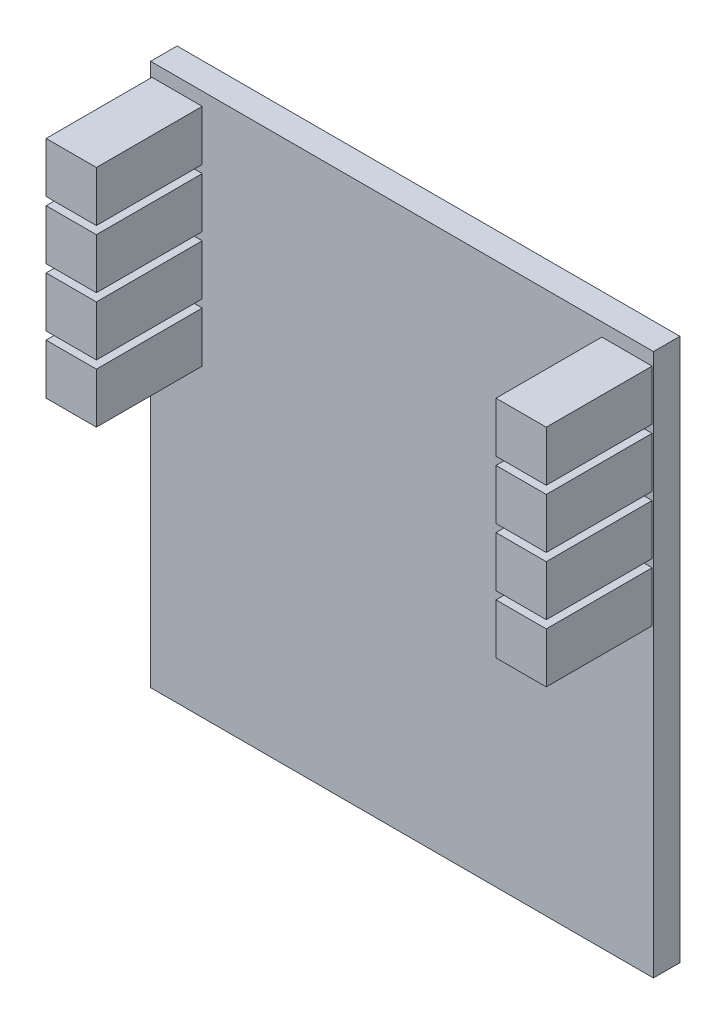
from build123d import *

# Parameters (mm, degrees)
SKETCH_1_W        = 19
SKETCH_1_H        = 20.5
EXTRUDE_1_DEPTH   = 1
SKETCH_2_W        = 1.9
SKETCH_2_H        = 1.9
EXTRUDE_2_DEPTH   = 4
EXTRUDE_2_2_DEPTH = 4
EXTRUDE_2_3_DEPTH = 4
EXTRUDE_2_4_DEPTH = 4
EXTRUDE_2_5_DEPTH = 4
EXTRUDE_2_6_DEPTH = 4
EXTRUDE_2_7_DEPTH = 4
EXTRUDE_2_8_DEPTH = 4
SKETCH_3_W        = 9
SKETCH_3_H        = 8
EXTRUDE_3_DEPTH   = 2.5
SKETCH_4_W        = 1.5
SKETCH_4_H        = 8
EXTRUDE_4_DEPTH   = 6


with BuildPart() as part:
    # ｽｹｯﾁ1 → ﾎﾞｽ - 押し出し1 (new body)
    with BuildSketch(Plane.XY):
        with Locations((9.5, 10.25)):
            Rectangle(SKETCH_1_W, SKETCH_1_H)
    extrude(amount=EXTRUDE_1_DEPTH)


with BuildPart() as body_2:
    # ｽｹｯﾁ2 → ﾎﾞｽ - 押し出し2 (new body)
    with BuildSketch(Plane.XY.offset(1)):
        with Locations((1, 19.05)):
            Rectangle(SKETCH_2_W, SKETCH_2_H)
    extrude(amount=EXTRUDE_2_DEPTH)


with BuildPart() as body_3:
    # ｽｹｯﾁ2 → Extrude 2 2 (new body)
    with BuildSketch(Plane.XY.offset(1)):
        with Locations((18, 19.05)):
            Rectangle(SKETCH_2_W, SKETCH_2_H)
    extrude(amount=EXTRUDE_2_2_DEPTH)


with BuildPart() as body_4:
    # ｽｹｯﾁ2 → Extrude 2 3 (new body)
    with BuildSketch(Plane.XY.offset(1)):
        with Locations((1, 16.85)):
            Rectangle(SKETCH_2_W, SKETCH_2_H)
    extrude(amount=EXTRUDE_2_3_DEPTH)


with BuildPart() as body_5:
    # ｽｹｯﾁ2 → Extrude 2 4 (new body)
    with BuildSketch(Plane.XY.offset(1)):
        with Locations((18, 16.85)):
            Rectangle(SKETCH_2_W, SKETCH_2_H)
    extrude(amount=EXTRUDE_2_4_DEPTH)


with BuildPart() as body_6:
    # ｽｹｯﾁ2 → Extrude 2 5 (new body)
    with BuildSketch(Plane.XY.offset(1)):
        with Locations((1, 14.65)):
            Rectangle(SKETCH_2_W, SKETCH_2_H)
    extrude(amount=EXTRUDE_2_5_DEPTH)


with BuildPart() as body_7:
    # ｽｹｯﾁ2 → Extrude 2 6 (new body)
    with BuildSketch(Plane.XY.offset(1)):
        with Locations((18, 14.65)):
            Rectangle(SKETCH_2_W, SKETCH_2_H)
    extrude(amount=EXTRUDE_2_6_DEPTH)


with BuildPart() as body_8:
    # ｽｹｯﾁ2 → Extrude 2 7 (new body)
    with BuildSketch(Plane.XY.offset(1)):
        with Locations((1, 12.45)):
            Rectangle(SKETCH_2_W, SKETCH_2_H)
    extrude(amount=EXTRUDE_2_7_DEPTH)


with BuildPart() as body_9:
    # ｽｹｯﾁ2 → Extrude 2 8 (new body)
    with BuildSketch(Plane.XY.offset(1)):
        with Locations((18, 12.45)):
            Rectangle(SKETCH_2_W, SKETCH_2_H)
    extrude(amount=EXTRUDE_2_8_DEPTH)


with BuildPart() as body_10:
    # ｽｹｯﾁ3 → ﾎﾞｽ - 押し出し3 (new body)
    with BuildSketch(Plane(origin=(0, 0, 0), x_dir=(-1, 0, 0), z_dir=(0, 0, -1))):
        with Locations((-4.5, 4)):
            Rectangle(SKETCH_3_W, SKETCH_3_H)
    extrude(amount=EXTRUDE_3_DEPTH)

    # ｽｹｯﾁ4 → ﾎﾞｽ - 押し出し4 (add)
    with BuildSketch(Plane(origin=(0, 0, -2.5), x_dir=(-1, 0, 0), z_dir=(0, 0, -1))):
        with Locations((-0.75, 4)):
            Rectangle(SKETCH_4_W, SKETCH_4_H)
    extrude(amount=EXTRUDE_4_DEPTH)


solid = Compound([part.part, body_2.part, body_3.part, body_4.part, body_5.part, body_6.part, body_7.part, body_8.part, body_9.part, body_10.part])
